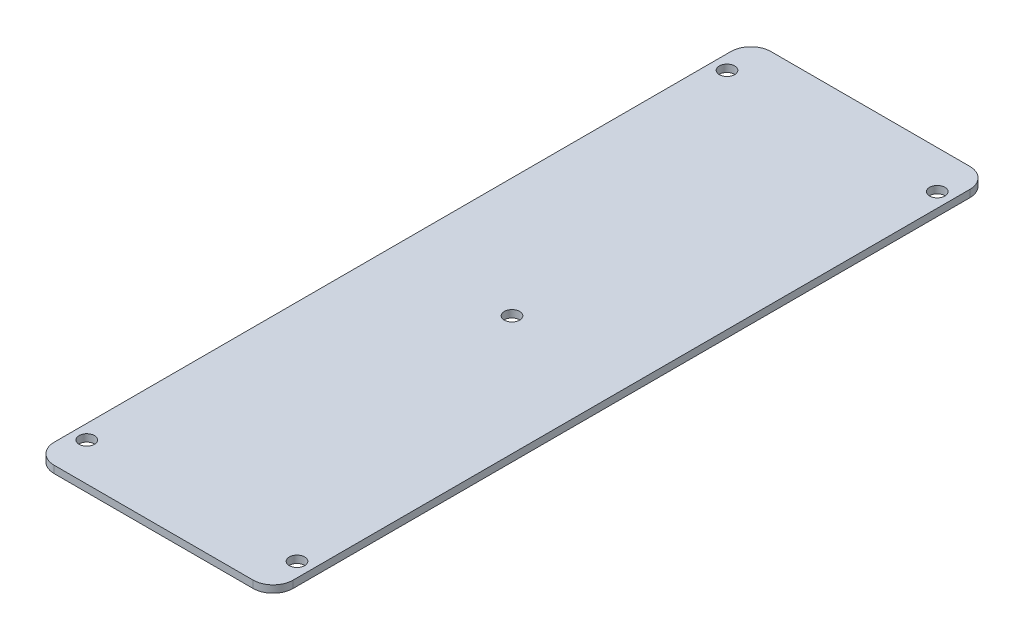
from build123d import *

# Parameters (mm, degrees)
SKETCH1_W            = 50
SKETCH1_H            = 150
BOSS_EXTRUDE1_DEPTH  = 1.524
SKETCH2_R            = 1.6
CUT_EXTRUDE1_DEPTH   = 1.524
LPATTERN1_COUNT      = 2
LPATTERN1_PITCH      = 44
LPATTERN1_COUNT_DIR2 = 2
LPATTERN1_PITCH_DIR2 = 134
FILLET1_R            = 4.191
SKETCH3_R            = 1.6
CUT_EXTRUDE2_DEPTH   = 1.524


with BuildPart() as part:
    # Sketch1 → Boss-Extrude1 (new body)
    with BuildSketch(Plane(origin=(0, 0, 0), x_dir=(1, 0, 0), z_dir=(0, 1, 0))):
        with Locations((25, -75)):
            Rectangle(SKETCH1_W, SKETCH1_H)
    extrude(amount=BOSS_EXTRUDE1_DEPTH)

    # Sketch2 → Cut-Extrude1 (cut)
    with BuildSketch(Plane(origin=(0, 1.524, 0), x_dir=(1, 0, 0), z_dir=(0, 1, 0))):
        with Locations((47, -8)):
            Circle(SKETCH2_R)
    cut_extrude1 = extrude(amount=-CUT_EXTRUDE1_DEPTH, mode=Mode.SUBTRACT)

    # LPattern1: Cut-Extrude1 2 × 2
    with Locations(*[(-i * LPATTERN1_PITCH, 0, j * LPATTERN1_PITCH_DIR2) for i in range(LPATTERN1_COUNT) for j in range(LPATTERN1_COUNT_DIR2) if (i, j) != (0, 0)]):
        add(cut_extrude1, mode=Mode.SUBTRACT)

    # Fillet1
    fillet1_edges = [part.edges().sort_by_distance(p)[0] for p in [
        (0, 0.762, 0),
        (50, 0.762, 0),
        (50, 0.762, 150),
        (0, 0.762, 150),
    ]]
    fillet(fillet1_edges, radius=FILLET1_R)

    # Sketch3 → Cut-Extrude2 (cut)
    with BuildSketch(Plane(origin=(0, 1.524, 0), x_dir=(1, 0, 0), z_dir=(0, 1, 0))):
        with Locations((25, -75)):
            Circle(SKETCH3_R)
    extrude(amount=-CUT_EXTRUDE2_DEPTH, mode=Mode.SUBTRACT)


solid = part.part
